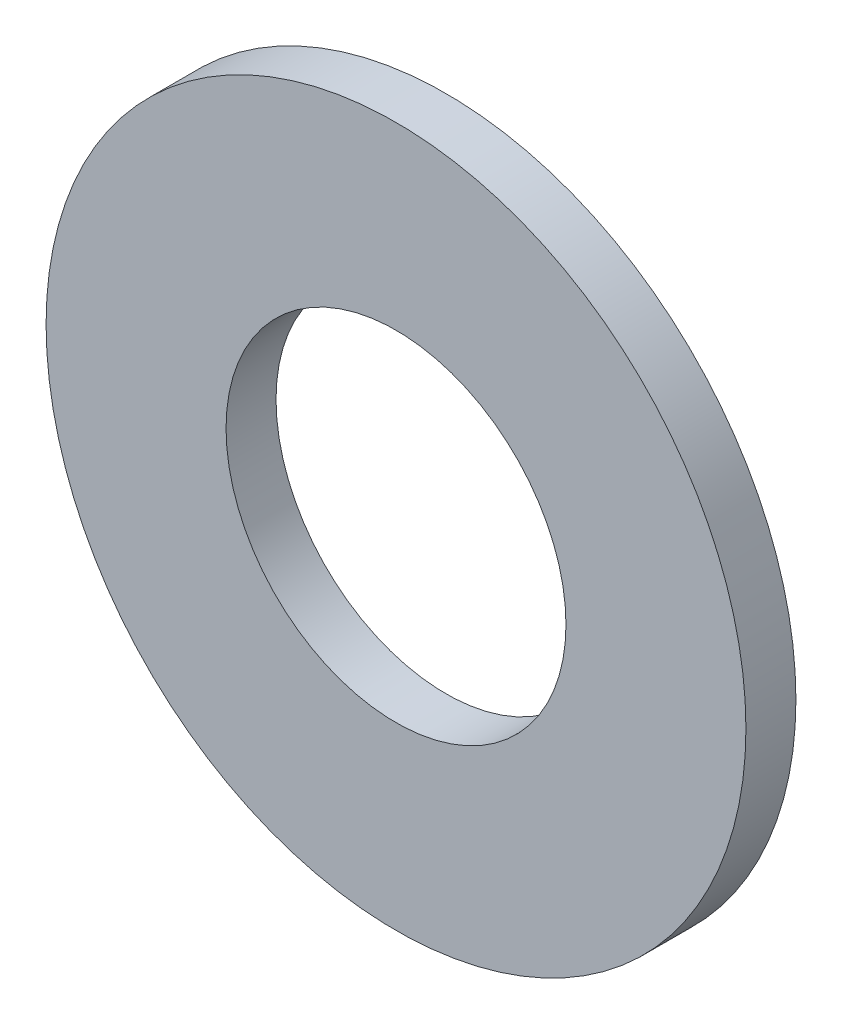
from build123d import *

# Parameters (mm, degrees)
SKETCH1_R          = 3.5
SKETCH1_R_2        = 1.7
BASE_EXTRUDE_DEPTH = 0.5


with BuildPart() as part:
    # Sketch1 → Base-Extrude (new body)
    with BuildSketch(Plane.XY):
        Circle(SKETCH1_R)
        Circle(SKETCH1_R_2, mode=Mode.SUBTRACT)
    extrude(amount=-BASE_EXTRUDE_DEPTH)


solid = part.part
